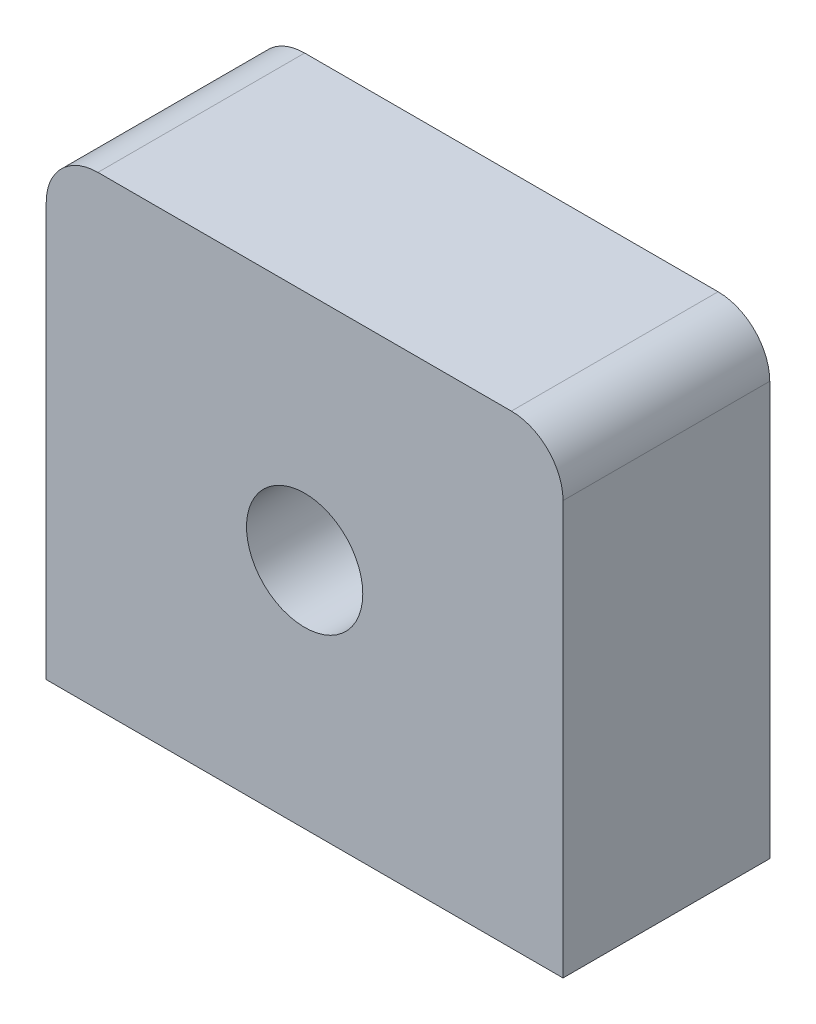
from build123d import *

# Parameters (mm, degrees)
SKETCH_1_R      = 2.25
EXTRUDE_1_DEPTH = 8


with BuildPart() as part:
    # Эскиз1 → Бобышка-Вытянуть1 (new body)
    with BuildSketch(Plane.XY):
        with BuildLine():
            Line((0, 0), (0, 16))
            ThreePointArc((0, 16), (0.585786438, 17.414213562), (2, 18))
            Line((2, 18), (18, 18))
            ThreePointArc((18, 18), (19.414213562, 17.414213562), (20, 16))
            Line((20, 16), (20, 0))
            Line((20, 0), (0, 0))
        make_face()
        with Locations((10, 9)):
            Circle(SKETCH_1_R, mode=Mode.SUBTRACT)
    extrude(amount=EXTRUDE_1_DEPTH)


solid = part.part
